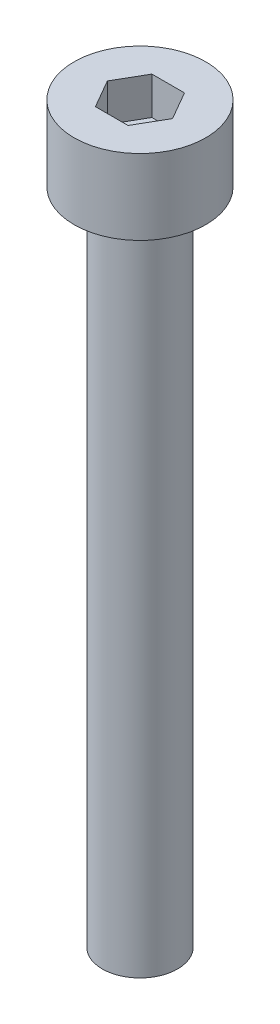
from build123d import *

# Parameters (mm, degrees)
SKETCH_1_R          = 3.5
EXTRUDE_397_DEPTH   = 4
SKETCH_1_3_R        = 2
EXTRUDE_432_DEPTH   = 35
CUT_EXTRUDE_1_DEPTH = 2


with BuildPart() as part:
    # 草图1 → Extrude 397 (new body)
    with BuildSketch(Plane(origin=(0, 0, 0), x_dir=(1, 0, 0), z_dir=(0, 1, 0))):
        Circle(SKETCH_1_R)
    extrude(amount=EXTRUDE_397_DEPTH)

    # 草图1<3> → Extrude 432 (add)
    with BuildSketch(Plane(origin=(0, 0, 0), x_dir=(1, 0, 0), z_dir=(0, 1, 0))):
        Circle(SKETCH_1_3_R)
    extrude(amount=-EXTRUDE_432_DEPTH)

    # 草图2 → 切除-拉伸1 (cut)
    with BuildSketch(Plane(origin=(0, 4, 0), x_dir=(1, 0, 0), z_dir=(0, 1, 0))):
        Polygon((1.732050808, 0), (0.866025404, 1.5), (-0.866025404, 1.5), (-1.732050808, 0), (-0.866025404, -1.5), (0.866025404, -1.5), align=None)
    extrude(amount=-CUT_EXTRUDE_1_DEPTH, mode=Mode.SUBTRACT)


solid = part.part
